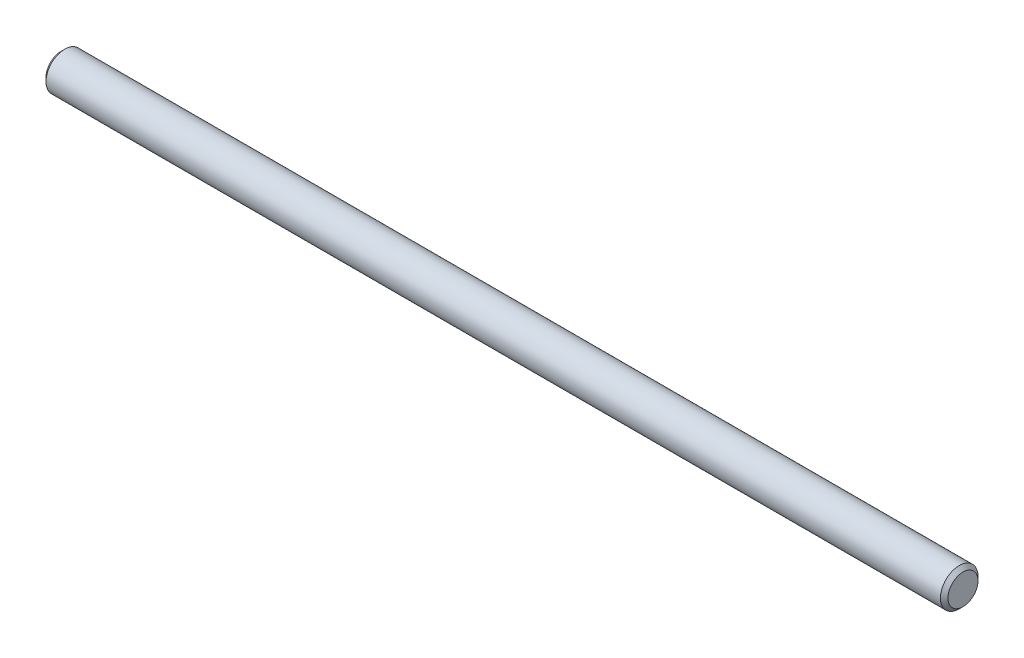
from build123d import *

# Parameters (mm, degrees)
SKETCH2_R           = 0.79375
EXTRUDE1_DEPTH      = 19.05
EXTRUDE1_DEPTH_BACK = 19.05
CHAMFER1_SIZE       = 0.15875


with BuildPart() as part:
    # Sketch2 → Extrude1 (new body, two sides)
    with BuildSketch(Plane(origin=(0, 0, 0), x_dir=(0, 0, -1), z_dir=(1, 0, 0))) as extrude1_sk:
        Circle(SKETCH2_R)
    extrude(amount=EXTRUDE1_DEPTH)
    extrude(extrude1_sk.sketch, amount=-EXTRUDE1_DEPTH_BACK)

    # Chamfer1
    chamfer1_edges = [part.edges().sort_by_distance(p)[0] for p in [
        (-19.05, 0, 0.79375),
        (19.05, 0, 0.79375),
    ]]
    chamfer(chamfer1_edges, length=CHAMFER1_SIZE)


solid = part.part
